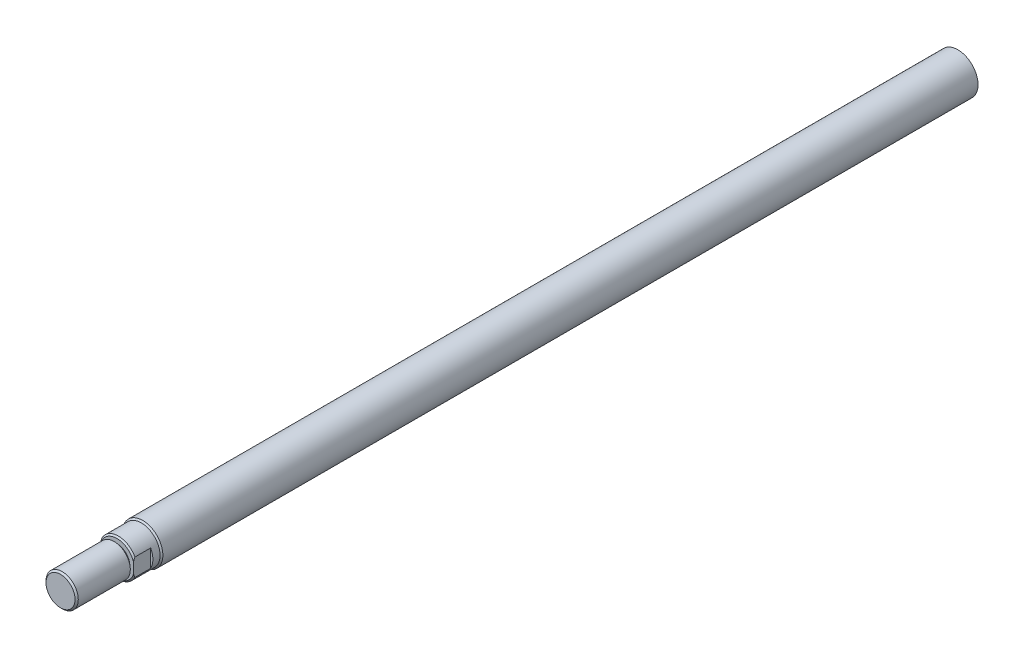
from build123d import *

# Parameters (mm, degrees)
CUT_EXTRUDE_START   = -8.5
CUT_EXTRUDE_5_DEPTH = 8.5
CHAMFER_2_SIZE      = 0.8


with BuildPart() as part:
    # 草图16 → 旋转1 (revolve)
    with BuildSketch(Plane(origin=(0, 0, 0), x_dir=(0, 0, -1), z_dir=(1, 0, 0))):
        Polygon((-45, 0), (-45, 8), (-18.4, 8), (-18.4, 6.4), (-17, 6.4), (-17, 8.6), (-16.3, 9.3), (-4.95, 9.3), (-4.25, 10), (0, 10), (400, 10), (400, 0), align=None)
    revolve(axis=Axis((0, 0, -400), (0, 0, 1)))

    # 草图17 → 切除-拉伸5 (cut)
    with BuildSketch(Plane.XY.offset(17).offset(CUT_EXTRUDE_START)):
        with BuildLine():
            Line((8.2, 4.387482194), (8.2, -4.387482194))
            ThreePointArc((8.2, -4.387482194), (9.3, 0), (8.2, 4.387482194))
        make_face()
        with BuildLine():
            Line((-8.2, 4.387482194), (-8.2, -4.387482194))
            ThreePointArc((-8.2, -4.387482194), (-9.3, 0), (-8.2, 4.387482194))
        make_face()
    extrude(amount=CUT_EXTRUDE_5_DEPTH, mode=Mode.SUBTRACT)

    # 倒角2
    chamfer_2_edges = [part.edges().sort_by_distance(p)[0] for p in [
        (0, -8, 45),
    ]]
    chamfer(chamfer_2_edges, length=CHAMFER_2_SIZE)


solid = part.part
